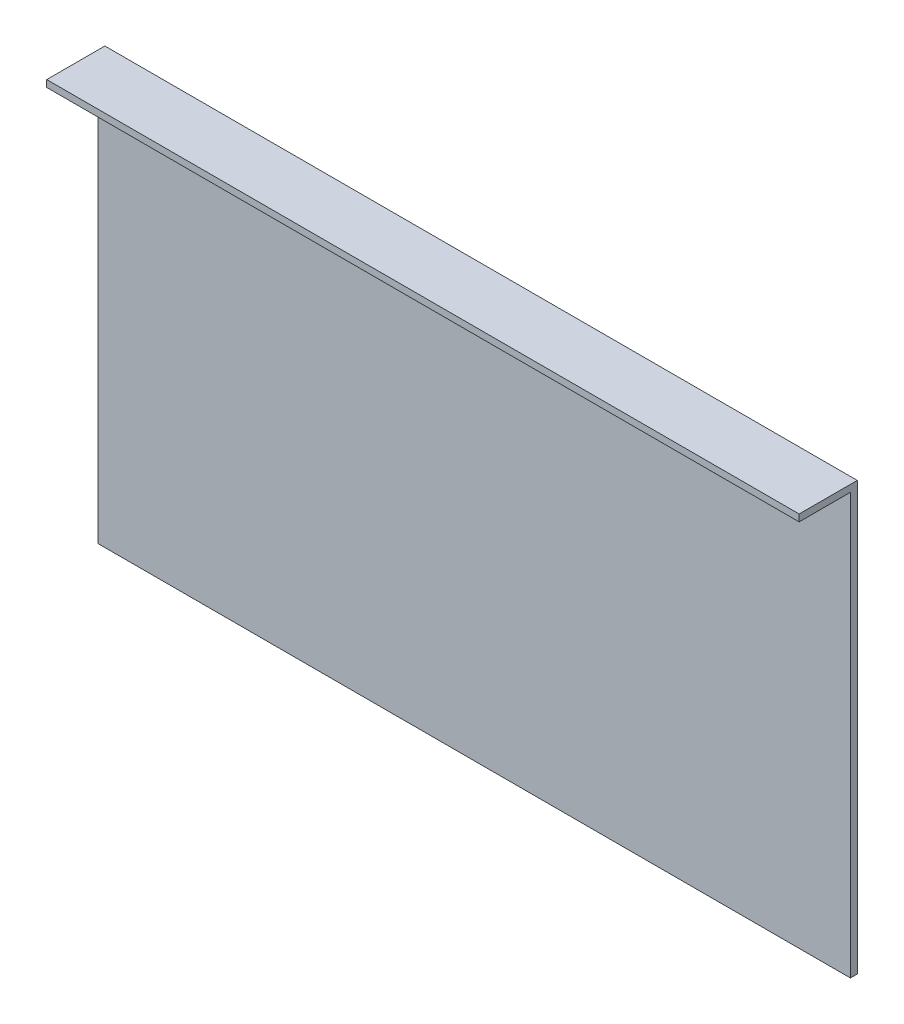
from build123d import *

# Parameters (mm, degrees)
SKETCH1_W           = 440
SKETCH1_H           = 250
BOSS_EXTRUDE1_DEPTH = 4
SKETCH2_W           = 440
SKETCH2_H           = 4
BOSS_EXTRUDE2_DEPTH = 30


with BuildPart() as part:
    # Sketch1 → Boss-Extrude1 (new body)
    with BuildSketch(Plane.XY):
        with Locations((220, 125)):
            Rectangle(SKETCH1_W, SKETCH1_H)
    extrude(amount=BOSS_EXTRUDE1_DEPTH)

    # Sketch2 → Boss-Extrude2 (add)
    with BuildSketch(Plane.XY.offset(4)):
        with Locations((220, 248)):
            Rectangle(SKETCH2_W, SKETCH2_H)
    extrude(amount=BOSS_EXTRUDE2_DEPTH)


solid = part.part
